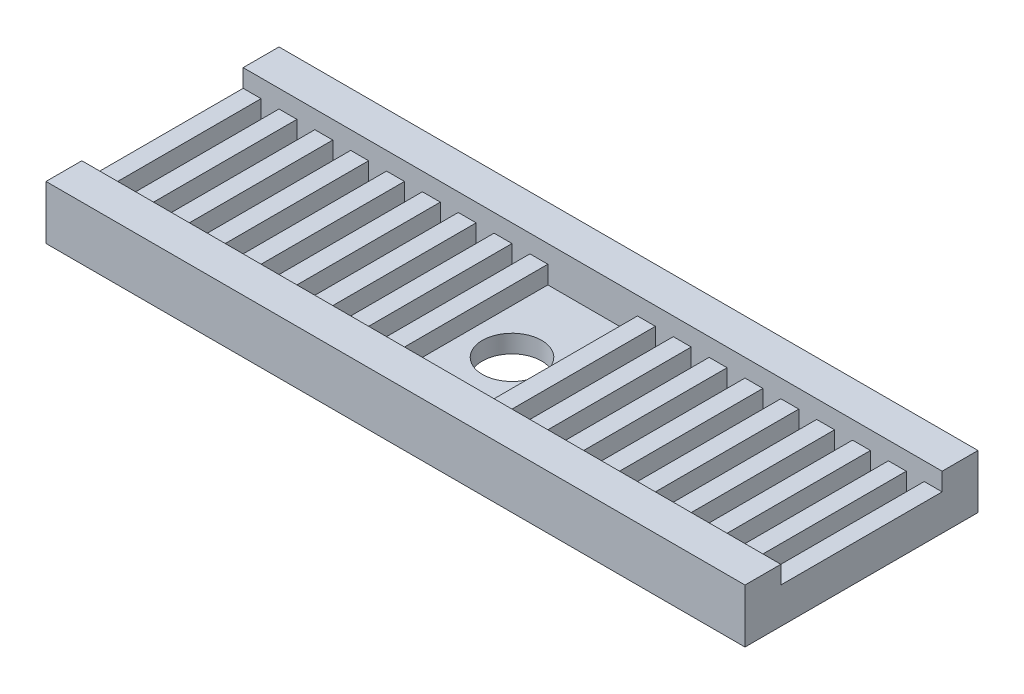
from build123d import *

# Parameters (mm, degrees)
SKETCH1_W           = 39
SKETCH1_H           = 13
BOSS_EXTRUDE1_DEPTH = 3
SKETCH5_W           = 39
SKETCH5_H           = 9
CUT_EXTRUDE1_DEPTH  = 2
SKETCH2_W           = 1
SKETCH2_H           = 9
BOSS_EXTRUDE2_DEPTH = 1
SKETCH6_R           = 1.65
CUT_EXTRUDE2_DEPTH  = 4


with BuildPart() as part:
    # Sketch1 → Boss-Extrude1 (new body)
    with BuildSketch(Plane(origin=(0, 0, 0), x_dir=(1, 0, 0), z_dir=(0, 1, 0))):
        Rectangle(SKETCH1_W, SKETCH1_H)
    extrude(amount=BOSS_EXTRUDE1_DEPTH)

    # Sketch5 → Cut-Extrude1 (cut)
    with BuildSketch(Plane(origin=(0, 3, 0), x_dir=(1, 0, 0), z_dir=(0, 1, 0))):
        Rectangle(SKETCH5_W, SKETCH5_H)
    extrude(amount=-CUT_EXTRUDE1_DEPTH, mode=Mode.SUBTRACT)

    # Sketch2 → Boss-Extrude2 (add)
    with BuildSketch(Plane(origin=(0, 1, 0), x_dir=(1, 0, 0), z_dir=(0, 1, 0))):
        with Locations((7, 0)):
            Rectangle(SKETCH2_W, SKETCH2_H)
        with Locations((5, 0)):
            Rectangle(SKETCH2_W, SKETCH2_H)
        with Locations((9, 0)):
            Rectangle(SKETCH2_W, SKETCH2_H)
        with Locations((3, 0)):
            Rectangle(SKETCH2_W, SKETCH2_H)
        with Locations((11, 0)):
            Rectangle(SKETCH2_W, SKETCH2_H)
        with Locations((13, 0)):
            Rectangle(SKETCH2_W, SKETCH2_H)
        with Locations((15, 0)):
            Rectangle(SKETCH2_W, SKETCH2_H)
        with Locations((-3, 0)):
            Rectangle(SKETCH2_W, SKETCH2_H)
        with Locations((17, 0)):
            Rectangle(SKETCH2_W, SKETCH2_H)
        with Locations((-5, 0)):
            Rectangle(SKETCH2_W, SKETCH2_H)
        with Locations((19, 0)):
            Rectangle(SKETCH2_W, SKETCH2_H)
        with Locations((-7, 0)):
            Rectangle(SKETCH2_W, SKETCH2_H)
        with Locations((-9, 0)):
            Rectangle(SKETCH2_W, SKETCH2_H)
        with Locations((-11, 0)):
            Rectangle(SKETCH2_W, SKETCH2_H)
        with Locations((-13, 0)):
            Rectangle(SKETCH2_W, SKETCH2_H)
        with Locations((-15, 0)):
            Rectangle(SKETCH2_W, SKETCH2_H)
        with Locations((-17, 0)):
            Rectangle(SKETCH2_W, SKETCH2_H)
        with Locations((-19, 0)):
            Rectangle(SKETCH2_W, SKETCH2_H)
    extrude(amount=BOSS_EXTRUDE2_DEPTH)

    # Sketch6 → Cut-Extrude2 (cut, through all)
    with BuildSketch(Plane.XZ):
        Circle(SKETCH6_R)
    extrude(amount=-CUT_EXTRUDE2_DEPTH, mode=Mode.SUBTRACT)


solid = part.part
